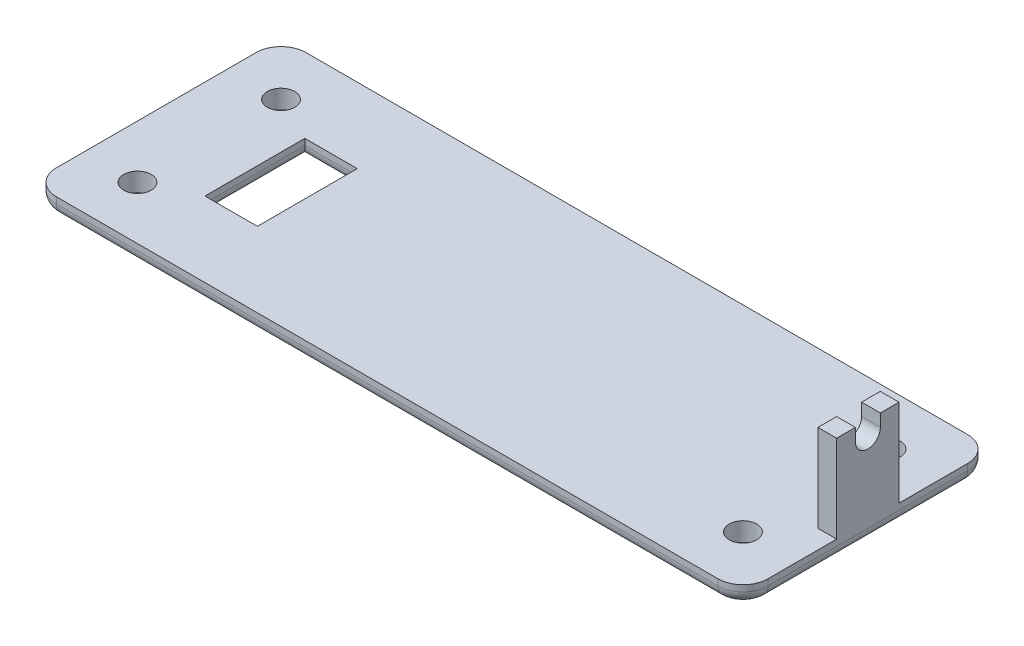
from build123d import *

# Parameters (mm, degrees)
SKETCH1_W           = 144.78
SKETCH1_H           = 50.8
BOSS_EXTRUDE1_DEPTH = 3.81
SKETCH2_W           = 3.81
SKETCH2_H           = 12.7
BOSS_EXTRUDE2_DEPTH = 17.78
CUT_EXTRUDE1_REACH  = 146.78
SKETCH4_W           = 10.668
SKETCH4_H           = 20.32
CUT_EXTRUDE2_DEPTH  = 22.59
SKETCH5_R           = 2.794
CUT_EXTRUDE3_DEPTH  = 22.59
FILLET3_R           = 5.08
FILLET4_R           = 2.54


with BuildPart() as part:
    # Sketch1 → Boss-Extrude1 (new body)
    with BuildSketch(Plane(origin=(0, 0, 0), x_dir=(1, 0, 0), z_dir=(0, 1, 0))):
        Rectangle(SKETCH1_W, SKETCH1_H)
    extrude(amount=BOSS_EXTRUDE1_DEPTH)

    # Sketch2 → Boss-Extrude2 (add)
    with BuildSketch(Plane(origin=(0, 3.81, 0), x_dir=(1, 0, 0), z_dir=(0, 1, 0))):
        with Locations((70.485, 0)):
            Rectangle(SKETCH2_W, SKETCH2_H)
    extrude(amount=BOSS_EXTRUDE2_DEPTH)

    # Sketch3 → Cut-Extrude1 (cut, up to next)
    with BuildSketch(Plane(origin=(72.39, 0, 0), x_dir=(0, 0, -1), z_dir=(1, 0, 0)), mode=Mode.PRIVATE) as cut_extrude1_sk1:
        with BuildLine():
            Line((-2.54, 21.59), (2.54, 21.59))
            Line((2.54, 21.59), (2.54, 19.05))
            ThreePointArc((2.54, 19.05), (0, 16.51), (-2.54, 19.05))
            Line((-2.54, 19.05), (-2.54, 21.59))
        make_face()
    cut_extrude1_tool1 = extrude(cut_extrude1_sk1.sketch, amount=-CUT_EXTRUDE1_REACH, mode=Mode.PRIVATE) & part.part
    add(cut_extrude1_tool1.solids().sort_by_distance((72.39, 19.287109, 0))[0], mode=Mode.SUBTRACT)

    # Sketch4 → Cut-Extrude2 (cut, through all)
    with BuildSketch(Plane.XZ):
        with Locations((-46.976, 0)):
            Rectangle(SKETCH4_W, SKETCH4_H)
    extrude(amount=-CUT_EXTRUDE2_DEPTH, mode=Mode.SUBTRACT)

    # Sketch5 → Cut-Extrude3 (cut, through all)
    with BuildSketch(Plane.XZ):
        with Locations((61.595, -14.605)):
            Circle(SKETCH5_R)
        with Locations((61.595, 14.605)):
            Circle(SKETCH5_R)
        with Locations((-61.595, 14.605)):
            Circle(SKETCH5_R)
        with Locations((-61.595, -14.605)):
            Circle(SKETCH5_R)
    extrude(amount=-CUT_EXTRUDE3_DEPTH, mode=Mode.SUBTRACT)

    # Fillet3
    fillet3_edges = [part.edges().sort_by_distance(p)[0] for p in [
        (72.39, 1.905, 25.4),
        (-72.39, 1.905, 25.4),
        (-72.39, 1.905, -25.4),
        (72.39, 1.905, -25.4),
    ]]
    fillet(fillet3_edges, radius=FILLET3_R)

    # Fillet4
    fillet4_edges = [part.edges().sort_by_distance(p)[0] for p in [
        (-52.31, 0, 0),
        (-46.976, 0, -10.16),
        (-41.642, 0, 0),
        (-46.976, 0, 10.16),
        (-72.39, 0, 0),
        (72.39, 0, 0),
        (0, 0, 25.4),
        (0, 0, -25.4),
        (70.902102448, 0, -23.912102448),
        (70.902102448, 0, 23.912102448),
        (-70.902102448, 0, 23.912102448),
        (-70.902102448, 0, -23.912102448),
    ]]
    fillet(fillet4_edges, radius=FILLET4_R)


solid = part.part
